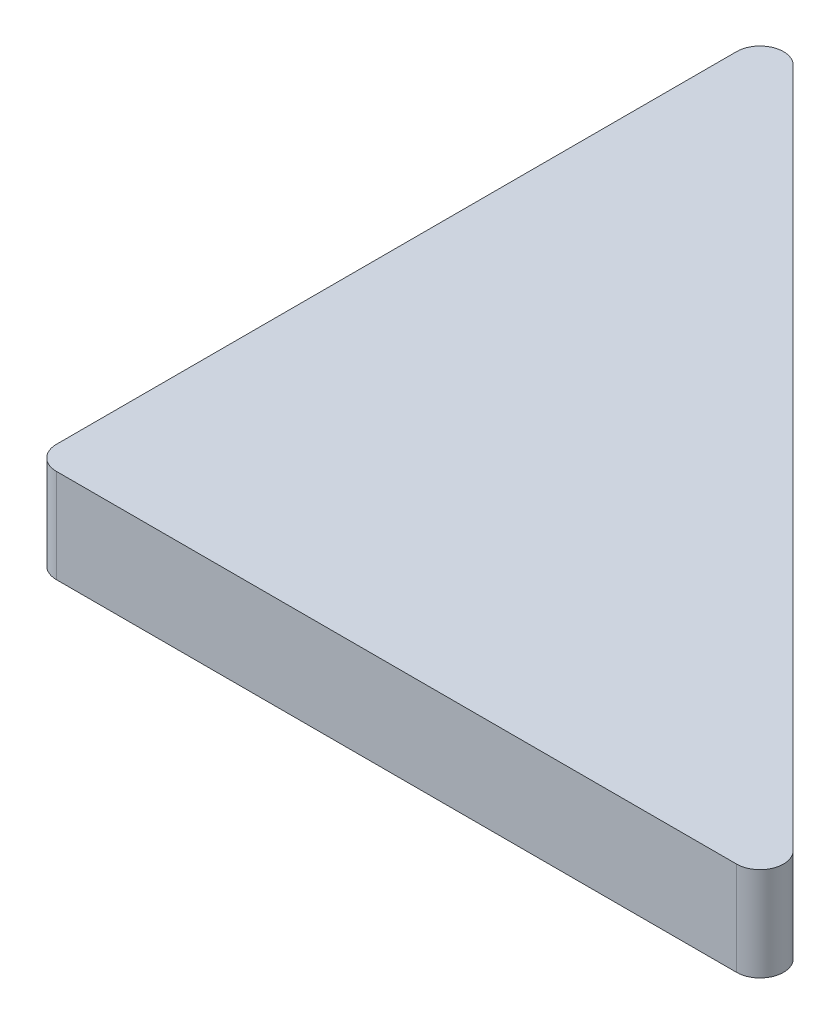
from build123d import *

# Parameters (mm, degrees)
BOSS_EXTRUDE1_DEPTH = 10


with BuildPart() as part:
    # Sketch2 → Boss-Extrude1 (new body)
    with BuildSketch(Plane(origin=(0, 0, 0), x_dir=(1, 0, 0), z_dir=(0, 1, 0))):
        with BuildLine():
            Line((4.267766953, 76.762899821), (76.762899821, 4.267766953))
            ThreePointArc((76.762899821, 4.267766953), (77.304831699, 1.543291419), (74.995132868, 0))
            Line((74.995132868, 0), (2.5, 0))
            ThreePointArc((2.5, 0), (0.732233047, 0.732233047), (0, 2.5))
            Line((0, 2.5), (0, 74.995132868))
            ThreePointArc((0, 74.995132868), (1.543291419, 77.304831699), (4.267766953, 76.762899821))
        make_face()
    extrude(amount=BOSS_EXTRUDE1_DEPTH)


solid = part.part
